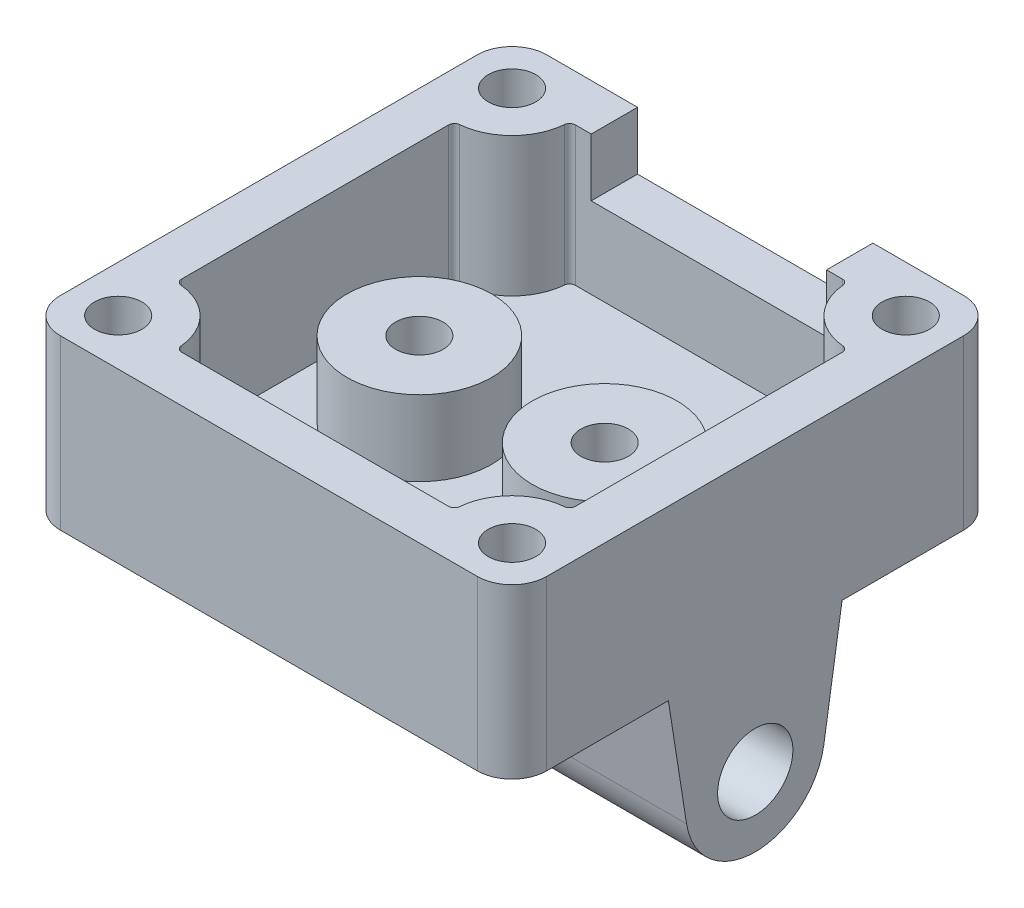
from build123d import *

# Parameters (mm, degrees)
SKETCH1_W           = 42
SKETCH1_H           = 42
BOSS_EXTRUDE1_DEPTH = 2.54
SKETCH2_W           = 42
SKETCH2_H           = 42
BOSS_EXTRUDE2_DEPTH = 12
SKETCH4_R           = 3.25
BOSS_EXTRUDE4_DEPTH = 42
SKETCH9_R           = 6.25
SKETCH9_R_2         = 2.05
BOSS_EXTRUDE5_DEPTH = 6.5
SKETCH10_R          = 2.05
CUT_EXTRUDE1_DEPTH  = 8
SKETCH12_W          = 20.32
SKETCH12_H          = 5
CUT_EXTRUDE2_DEPTH  = 4
FILLET1_R           = 3


with BuildPart() as part:
    # Sketch1 → Boss-Extrude1 (new body)
    with BuildSketch(Plane(origin=(0, 0, 0), x_dir=(1, 0, 0), z_dir=(0, 1, 0))):
        Rectangle(SKETCH1_W, SKETCH1_H)
    extrude(amount=BOSS_EXTRUDE1_DEPTH)

    # Sketch2 → Boss-Extrude2 (add)
    with BuildSketch(Plane(origin=(0, 2.54, 0), x_dir=(1, 0, 0), z_dir=(0, 1, 0))):
        Rectangle(SKETCH2_W, SKETCH2_H)
        with BuildLine():
            Line((-17, 11.522774425), (-17, -11.522774425))
            ThreePointArc((-17, -11.522774425), (-16.869274473, -11.859874356), (-16.545454545, -12.020704023))
            ThreePointArc((-16.545454545, -12.020704023), (-13.464466094, -13.464466094), (-12.020704023, -16.545454545))
            ThreePointArc((-12.020704023, -16.545454545), (-11.859874356, -16.869274473), (-11.522774425, -17))
            Line((-11.522774425, -17), (11.522774425, -17))
            ThreePointArc((11.522774425, -17), (11.859874356, -16.869274473), (12.020704023, -16.545454545))
            ThreePointArc((12.020704023, -16.545454545), (13.464466094, -13.464466094), (16.545454545, -12.020704023))
            ThreePointArc((16.545454545, -12.020704023), (16.869274473, -11.859874356), (17, -11.522774425))
            Line((17, -11.522774425), (17, 11.522774425))
            ThreePointArc((17, 11.522774425), (16.869274473, 11.859874356), (16.545454545, 12.020704023))
            ThreePointArc((16.545454545, 12.020704023), (13.464466094, 13.464466094), (12.020704023, 16.545454545))
            ThreePointArc((12.020704023, 16.545454545), (11.859874356, 16.869274473), (11.522774425, 17))
            Line((11.522774425, 17), (-11.522774425, 17))
            ThreePointArc((-11.522774425, 17), (-11.859874356, 16.869274473), (-12.020704023, 16.545454545))
            ThreePointArc((-12.020704023, 16.545454545), (-13.464466094, 13.464466094), (-16.545454545, 12.020704023))
            ThreePointArc((-16.545454545, 12.020704023), (-16.869274473, 11.859874356), (-17, 11.522774425))
        make_face(mode=Mode.SUBTRACT)
    extrude(amount=BOSS_EXTRUDE2_DEPTH)

    # Sketch4 → Boss-Extrude4 (add)
    with BuildSketch(Plane.ZY.offset(21)):
        with BuildLine():
            Line((7.5, 0), (5.927131841, -10))
            ThreePointArc((5.927131841, -10), (0, -15.067740305), (-5.927131841, -10))
            Line((-5.927131841, -10), (-7.5, 0))
            Line((-7.5, 0), (7.5, 0))
        make_face()
        with Locations((0, -9.067740305)):
            Circle(SKETCH4_R, mode=Mode.SUBTRACT)
    extrude(amount=-BOSS_EXTRUDE4_DEPTH)

    # Sketch9 → Boss-Extrude5 (add)
    with BuildSketch(Plane(origin=(0, 2.54, 0), x_dir=(1, 0, 0), z_dir=(0, 1, 0))):
        with Locations((8, 0)):
            Circle(SKETCH9_R)
        with Locations((8, 0)):
            Circle(SKETCH9_R_2, mode=Mode.SUBTRACT)
        with Locations((-8, 0)):
            Circle(SKETCH9_R)
        with Locations((-8, 0)):
            Circle(SKETCH9_R_2, mode=Mode.SUBTRACT)
    extrude(amount=BOSS_EXTRUDE5_DEPTH)

    # Sketch10 → Cut-Extrude1 (cut)
    with BuildSketch(Plane(origin=(0, 14.54, 0), x_dir=(1, 0, 0), z_dir=(0, 1, 0))):
        with Locations((-17, 17)):
            Circle(SKETCH10_R)
        with Locations((17, 17)):
            Circle(SKETCH10_R)
        with Locations((-17, -17)):
            Circle(SKETCH10_R)
        with Locations((17, -17)):
            Circle(SKETCH10_R)
    extrude(amount=-CUT_EXTRUDE1_DEPTH, mode=Mode.SUBTRACT)

    # Sketch12 → Cut-Extrude2 (cut)
    with BuildSketch(Plane(origin=(0, 0, -21), x_dir=(-1, 0, 0), z_dir=(0, 0, -1))):
        with Locations((0, 12.04)):
            Rectangle(SKETCH12_W, SKETCH12_H)
    extrude(amount=-CUT_EXTRUDE2_DEPTH, mode=Mode.SUBTRACT)

    # Fillet1
    fillet1_edges = [part.edges().sort_by_distance(p)[0] for p in [
        (21, 7.27, 21),
        (-21, 7.27, 21),
        (-21, 7.27, -21),
        (21, 7.27, -21),
    ]]
    fillet(fillet1_edges, radius=FILLET1_R)


solid = part.part
